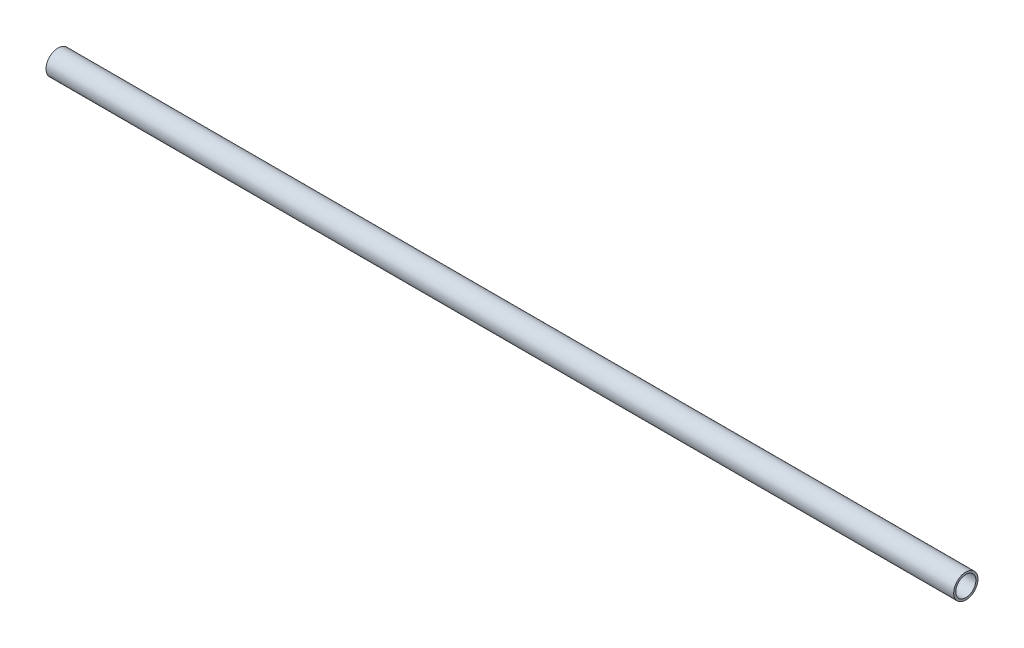
from build123d import *

# Parameters (mm, degrees)
SKETCH1_R           = 9.525
SKETCH1_R_2         = 7.874
BOSS_EXTRUDE1_DEPTH = 355.6


with BuildPart() as part:
    # Sketch1 → Boss-Extrude1 (new body, symmetric)
    with BuildSketch(Plane(origin=(0, 0, 0), x_dir=(0, 0, -1), z_dir=(1, 0, 0))):
        Circle(SKETCH1_R)
        Circle(SKETCH1_R_2, mode=Mode.SUBTRACT)
    extrude(amount=BOSS_EXTRUDE1_DEPTH, both=True)


solid = part.part
